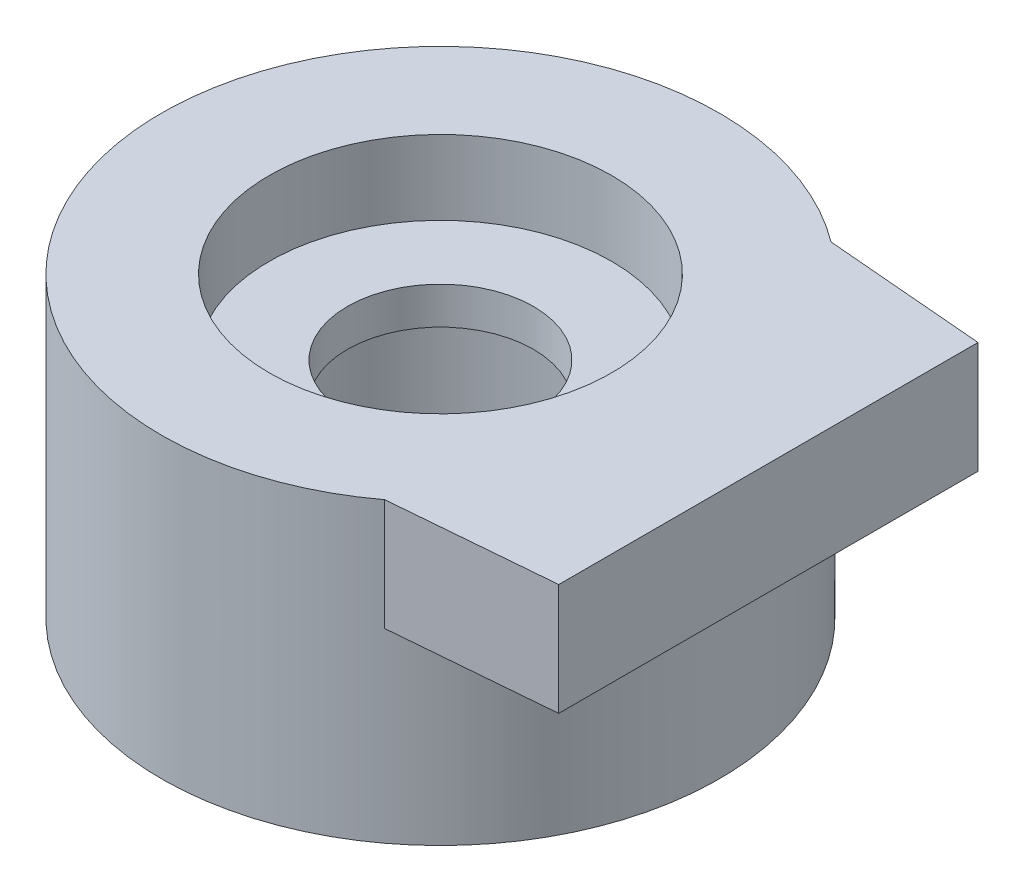
from build123d import *

# Parameters (mm, degrees)
BOSS_EXTRUDE1_DEPTH = 1.5
SKETCH2_R           = 3.75
BOSS_EXTRUDE2_DEPTH = 2.5


with BuildPart() as part:
    # Sketch1 → Boss-Extrude1 (new body)
    with BuildSketch(Plane(origin=(0, 4, 0), x_dir=(1, 0, 0), z_dir=(0, 1, 0))):
        with BuildLine():
            Line((2.25, -3), (4.407767894, -2.817669075))
            Line((4.407767894, -2.817669075), (4.407767894, 2.817669075))
            Line((4.407767894, 2.817669075), (2.25, 3))
            ThreePointArc((2.25, 3), (-3.75, 0), (2.25, -3))
        make_face()
    extrude(amount=-BOSS_EXTRUDE1_DEPTH)

    # Sketch2 → Boss-Extrude2 (add)
    with BuildSketch(Plane.XZ.offset(-2.5)):
        Circle(SKETCH2_R)
    extrude(amount=BOSS_EXTRUDE2_DEPTH)

    # Sketch3 → Cut-Revolve1 (revolve, cut)
    with BuildSketch(Plane(origin=(0, 0, 0), x_dir=(-1, 0, 0), z_dir=(0, 0, -1))):
        Polygon((-2.3, 0), (0, 0), (0, 4), (-2.3, 4), (-2.3, 3), (-1.25, 3), (-1.25, 2.5), (-2.3, 2.5), align=None)
    revolve(axis=Axis((0, 0, 0), (0, 1, 0)), mode=Mode.SUBTRACT)


solid = part.part
